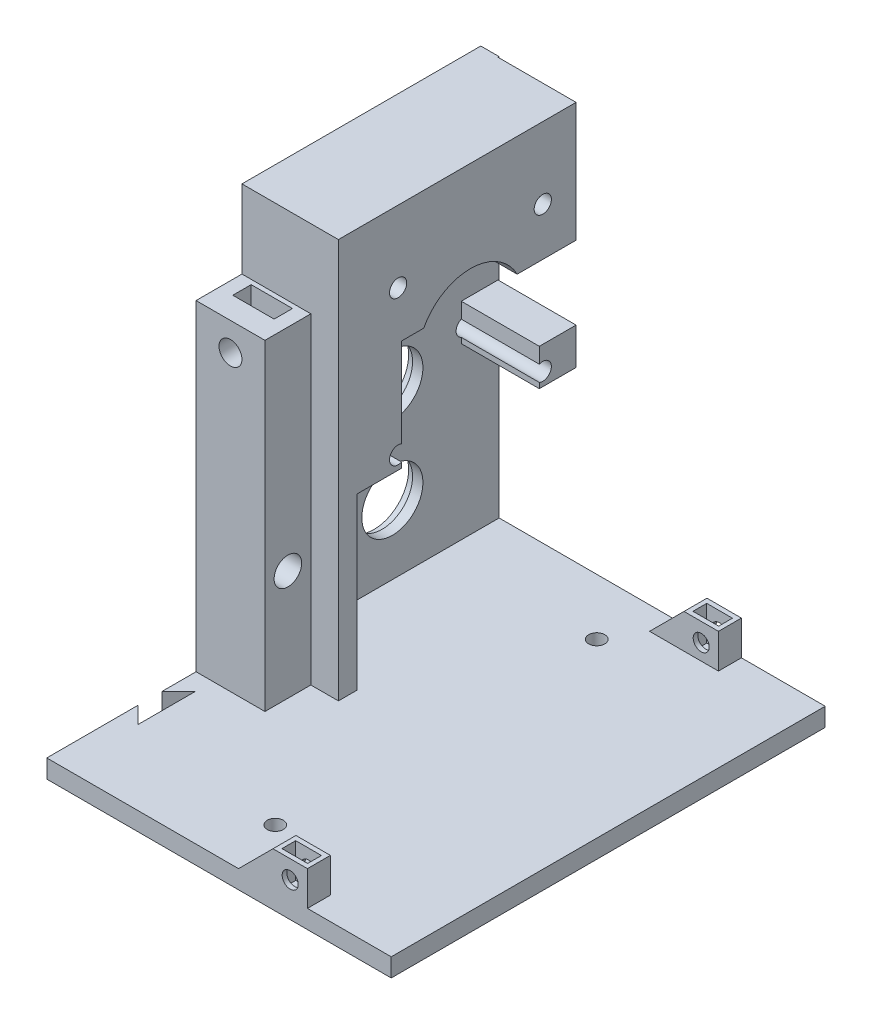
from build123d import *

# Parameters (mm, degrees)
SKETCH20_W                        = 75
SKETCH20_H                        = 94.5
BASE_DEPTH                        = 4
SKETCH21_W                        = 21
SKETCH21_H                        = 4
X_WALL_DEPTH                      = 87
SKETCH22_W                        = 4
SKETCH22_H                        = 48
Y_WALL_DEPTH                      = 87
SKETCH23_W                        = 15
SKETCH23_H                        = 10
BELT_SCREW_MOUNT_DEPTH            = 70
SKETCH24_W                        = 8
SKETCH24_H                        = 8
MOTOR_SPACER_DEPTH                = 17
SKETCH14_R                        = 6.65
SKETCH14_R_2                      = 3.75
SKETCH14_R_3                      = 1.875
MOTOR_BEARING_HOLES_DEPTH         = 21
SKETCH15_R                        = 7.55
BEARING_HOLES_2_DEPTH             = 1.75
SKETCH17_R                        = 2.5
BELT_SCREW_HOLE_DEPTH             = 8
SKETCH18_W                        = 9
SKETCH18_H                        = 4
BELT_BOLT_HOLE_DEPTH              = 10.35
SKETCH25_R                        = 11.5
MOTOR_CUTOUT_DEPTH                = 17
SKETCH26_R                        = 1.75
CONNECTOR_SCREW_HOLE_DEPTH        = 15
SKETCH42_R                        = 3
CUT_EXTRUDE2_DEPTH                = 7
DOVETAILCUTOUT_DEPTH              = 4.2
FRONT_RIGHT_CASE_SCREW_BODY_DEPTH = 5
SKETCH29_R                        = 1.75
FRONT_RIGHT_CASE_SCREW_HOLE_DEPTH = 10
SKETCH30_W                        = 5.6
SKETCH30_H                        = 3
FRONT_RIGHT_CASE_NUT_HOLE_DEPTH   = 7.5
BACK_RIGHT_CASE_SCREW_BODY_DEPTH  = 5
SKETCH38_R                        = 1.75
BACK_RIGHT_CASE_SCREW_HOLE_DEPTH  = 5
SKETCH39_W                        = 5.6
SKETCH39_H                        = 3
BACK_RIGHT_CASE_NUT_HOLE_DEPTH    = 7.5
SKETCH40_R                        = 1.75
FOOT_HOLES_DEPTH                  = 10
SKETCH41_R                        = 1.5
SKETCH41_W                        = 6
SKETCH41_H                        = 22
MOTOR_CABLE_PASSTHROUGH_DEPTH     = 4


with BuildPart() as part:
    # Sketch20 → Base (new body)
    with BuildSketch(Plane(origin=(0, 0, 0), x_dir=(1, 0, 0), z_dir=(0, 1, 0))):
        with Locations((37.5, -47.25)):
            Rectangle(SKETCH20_W, SKETCH20_H)
    extrude(amount=BASE_DEPTH)

    # Sketch21 → X_Wall (add)
    with BuildSketch(Plane(origin=(0, 4, 0), x_dir=(1, 0, 0), z_dir=(0, 1, 0))):
        with Locations((10.5, -50)):
            Rectangle(SKETCH21_W, SKETCH21_H)
    extrude(amount=X_WALL_DEPTH)

    # Sketch22 → Y_Wall (add)
    with BuildSketch(Plane(origin=(0, 4, 0), x_dir=(1, 0, 0), z_dir=(0, 1, 0))):
        with Locations((2, -24)):
            Rectangle(SKETCH22_W, SKETCH22_H)
    extrude(amount=Y_WALL_DEPTH)

    # Sketch23 → Belt_Screw_Mount (add)
    with BuildSketch(Plane(origin=(0, 4, 0), x_dir=(1, 0, 0), z_dir=(0, 1, 0))):
        with Locations((7.5, -57)):
            Rectangle(SKETCH23_W, SKETCH23_H)
    extrude(amount=BELT_SCREW_MOUNT_DEPTH)

    # Sketch24 → Motor_Spacer (add)
    with BuildSketch(Plane(origin=(4, 0, 0), x_dir=(0, 0, -1), z_dir=(1, 0, 0))):
        Polygon((-48, 41), (-48, 91), (-0.25, 91), (-0.25, 65), (-8.25, 65), (-38.25, 65), (-38.25, 41), align=None)
        with Locations((-4.25, 45)):
            Rectangle(SKETCH24_W, SKETCH24_H)
    extrude(amount=MOTOR_SPACER_DEPTH)

    # Sketch14 → Motor_Bearing_Holes (cut)
    with BuildSketch(Plane.ZY):
        with Locations((23.25, 19)):
            Circle(SKETCH14_R)
        with Locations((23.25, 40.65)):
            Circle(SKETCH14_R)
        with Locations((23.25, 59.65)):
            Circle(SKETCH14_R_2)
        with Locations((39, 75.4)):
            Circle(SKETCH14_R_3)
        with Locations((39, 43.9)):
            Circle(SKETCH14_R_3)
        with Locations((7.5, 43.9)):
            Circle(SKETCH14_R_3)
        with Locations((7.5, 75.4)):
            Circle(SKETCH14_R_3)
    extrude(amount=-MOTOR_BEARING_HOLES_DEPTH, mode=Mode.SUBTRACT)

    # Sketch15 → Bearing_Holes_2 (cut)
    with BuildSketch(Plane.ZY):
        with Locations((23.25, 19)):
            Circle(SKETCH15_R)
        with Locations((23.25, 40.65)):
            Circle(SKETCH15_R)
    extrude(amount=-BEARING_HOLES_2_DEPTH, mode=Mode.SUBTRACT)

    # Sketch17 → Belt_Screw_Hole (cut)
    with BuildSketch(Plane.XY.offset(62)):
        with Locations((7.5, 67.9)):
            Circle(SKETCH17_R)
    extrude(amount=-BELT_SCREW_HOLE_DEPTH, mode=Mode.SUBTRACT)

    # Sketch18 → Belt_Bolt_Hole (cut)
    with BuildSketch(Plane(origin=(0, 74, 0), x_dir=(1, 0, 0), z_dir=(0, 1, 0))):
        with Locations((7.5, -55)):
            Rectangle(SKETCH18_W, SKETCH18_H)
    extrude(amount=-BELT_BOLT_HOLE_DEPTH, mode=Mode.SUBTRACT)

    # Sketch25 → Motor_Cutout (cut)
    with BuildSketch(Plane(origin=(21, 0, 0), x_dir=(0, 0, -1), z_dir=(1, 0, 0))):
        with Locations((-23.25, 59.65)):
            Circle(SKETCH25_R)
    extrude(amount=-MOTOR_CUTOUT_DEPTH, mode=Mode.SUBTRACT)

    # Sketch26 → Connector_Screw-hole (cut)
    with BuildSketch(Plane.ZY):
        with Locations((57, 28)):
            Circle(SKETCH26_R)
    extrude(amount=-CONNECTOR_SCREW_HOLE_DEPTH, mode=Mode.SUBTRACT)

    # Sketch42 → Cut-Extrude2 (cut)
    with BuildSketch(Plane(origin=(15, 0, 0), x_dir=(0, 0, -1), z_dir=(1, 0, 0))):
        with Locations((-57, 28)):
            Circle(SKETCH42_R)
    extrude(amount=-CUT_EXTRUDE2_DEPTH, mode=Mode.SUBTRACT)

    # Sketch27 → DoveTailCutout (cut)
    with BuildSketch(Plane.XZ):
        Polygon((3.635533906, 65.723044738), (-0.1, 69.458578644), (-0.1, 74.541421356), (3.635533906, 78.276955262), align=None)
        Polygon((3.635533906, 16.223044738), (3.635533906, 28.776955262), (-0.1, 25.041421356), (-0.1, 19.958578644), align=None)
    extrude(amount=-DOVETAILCUTOUT_DEPTH, mode=Mode.SUBTRACT)

    # Sketch28 → Front_Right_Case_Screw_Body (add)
    with BuildSketch(Plane.XY.offset(94.5)):
        Polygon((56.75, 4), (56.75, 11.5), (49.25, 11.5), (41.75, 4), align=None)
    extrude(amount=-FRONT_RIGHT_CASE_SCREW_BODY_DEPTH)

    # Sketch29 → Front_Right_Case_Screw_Hole (cut)
    with BuildSketch(Plane.XY.offset(94.5)):
        with Locations((53, 7.5)):
            Circle(SKETCH29_R)
    extrude(amount=-FRONT_RIGHT_CASE_SCREW_HOLE_DEPTH, mode=Mode.SUBTRACT)

    # Sketch30 → Front_Right_Case_Nut_Hole (cut)
    with BuildSketch(Plane(origin=(0, 11.5, 0), x_dir=(1, 0, 0), z_dir=(0, 1, 0))):
        with Locations((53, -92)):
            Rectangle(SKETCH30_W, SKETCH30_H)
    extrude(amount=-FRONT_RIGHT_CASE_NUT_HOLE_DEPTH, mode=Mode.SUBTRACT)

    # Sketch40 → Foot_Holes (cut)
    with BuildSketch(Plane.XZ):
        with Locations((37.5, 82.25)):
            Circle(SKETCH40_R)
        with Locations((37.5, 12.25)):
            Circle(SKETCH40_R)
    extrude(amount=-FOOT_HOLES_DEPTH, mode=Mode.SUBTRACT)

    # Sketch41 → Motor_Cable_Passthrough (cut)
    with BuildSketch(Plane(origin=(4, 0, 0), x_dir=(0, 0, -1), z_dir=(1, 0, 0))):
        with Locations((-44.915, 11)):
            Circle(SKETCH41_R)
        with Locations((-44.915, 6)):
            Circle(SKETCH41_R)
        with Locations((-38.83, 15)):
            Rectangle(SKETCH41_W, SKETCH41_H)
    extrude(amount=-MOTOR_CABLE_PASSTHROUGH_DEPTH, mode=Mode.SUBTRACT)


with BuildPart() as body_2:
    # Sketch37 → Back_Right_Case_Screw_Body (new body)
    with BuildSketch(Plane(origin=(0, 0, 0), x_dir=(-1, 0, 0), z_dir=(0, 0, -1))):
        Polygon((-56.75, 4), (-56.75, 11.5), (-49.25, 11.5), (-41.75, 4), align=None)
    extrude(amount=-BACK_RIGHT_CASE_SCREW_BODY_DEPTH)

    # Sketch38 → Back_Right_Case_Screw_Hole (cut)
    with BuildSketch(Plane(origin=(0, 0, 0), x_dir=(-1, 0, 0), z_dir=(0, 0, -1))):
        with Locations((-53, 7.5)):
            Circle(SKETCH38_R)
    extrude(amount=-BACK_RIGHT_CASE_SCREW_HOLE_DEPTH, mode=Mode.SUBTRACT)

    # Sketch39 → Back_Right_Case_Nut_Hole (cut)
    with BuildSketch(Plane(origin=(0, 11.5, 0), x_dir=(1, 0, 0), z_dir=(0, 1, 0))):
        with Locations((53, -2.5)):
            Rectangle(SKETCH39_W, SKETCH39_H)
    extrude(amount=-BACK_RIGHT_CASE_NUT_HOLE_DEPTH, mode=Mode.SUBTRACT)


solid = Compound([part.part, body_2.part])
